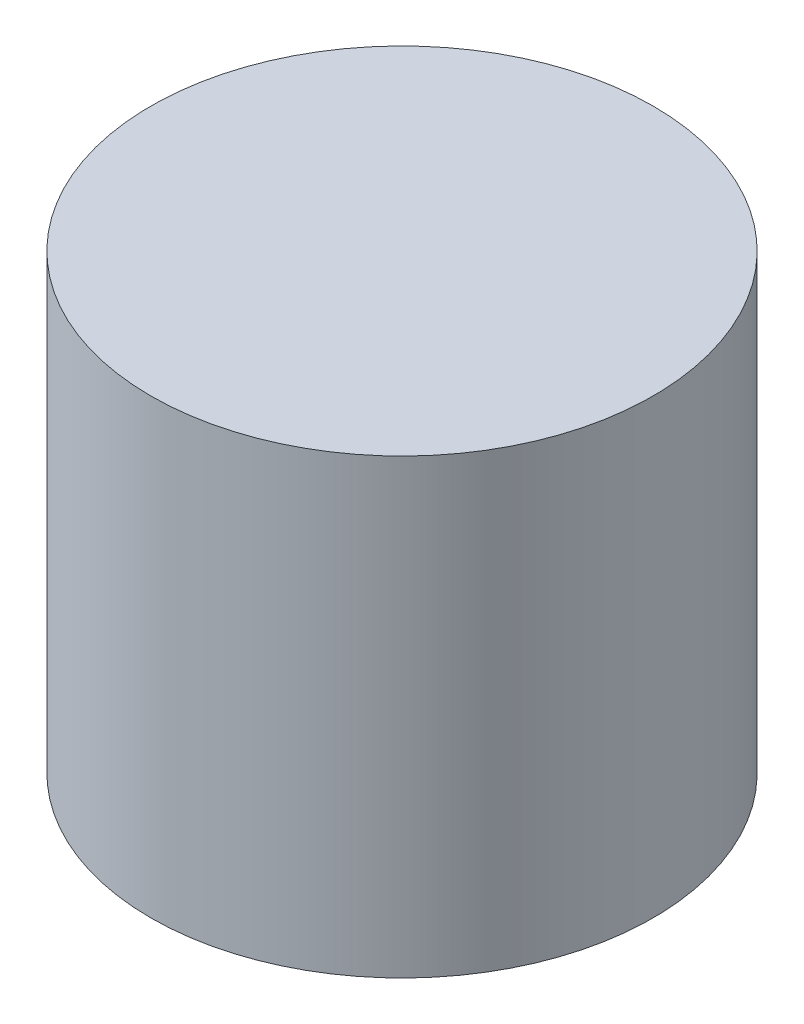
from build123d import *

# Parameters (mm, degrees)
SKETCH1_R           = 5
BOSS_EXTRUDE1_DEPTH = 9


with BuildPart() as part:
    # Sketch1 → Boss-Extrude1 (new body)
    with BuildSketch(Plane(origin=(0, 0, 0), x_dir=(1, 0, 0), z_dir=(0, 1, 0))):
        Circle(SKETCH1_R)
    extrude(amount=BOSS_EXTRUDE1_DEPTH)


solid = part.part
